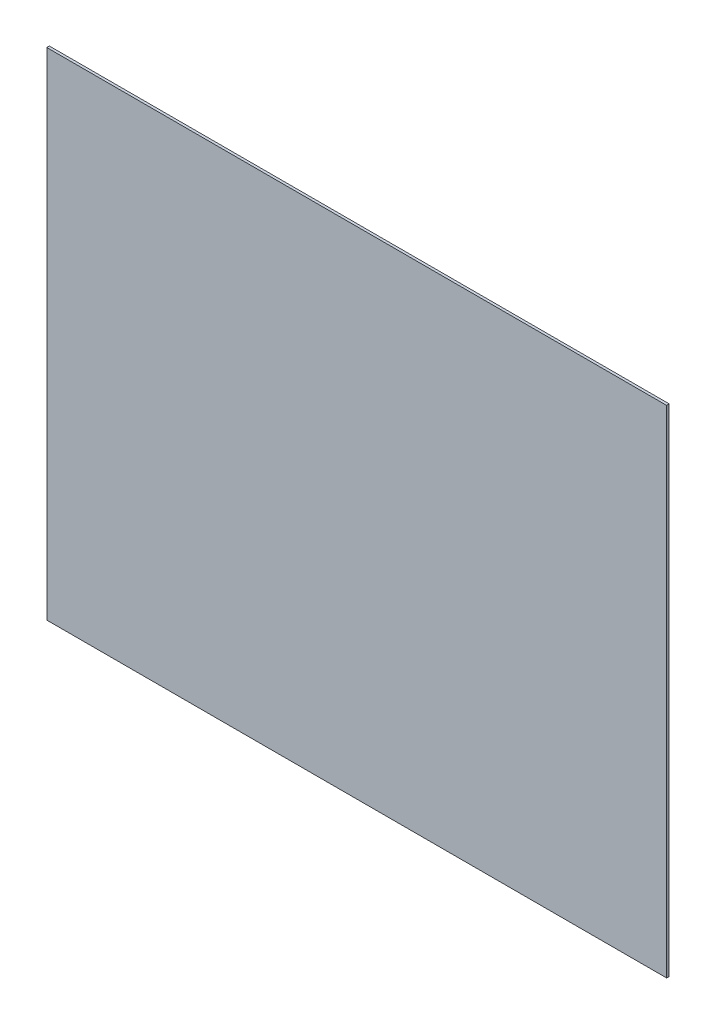
from build123d import *

# Parameters (mm, degrees)
SKETCH1_W      = 762
SKETCH1_H      = 609.6
EXTRUDE1_DEPTH = 3.175


with BuildPart() as part:
    # Sketch1 → Extrude1 (new body)
    with BuildSketch(Plane.XY):
        with Locations((381, 304.8)):
            Rectangle(SKETCH1_W, SKETCH1_H)
    extrude(amount=EXTRUDE1_DEPTH)


solid = part.part
